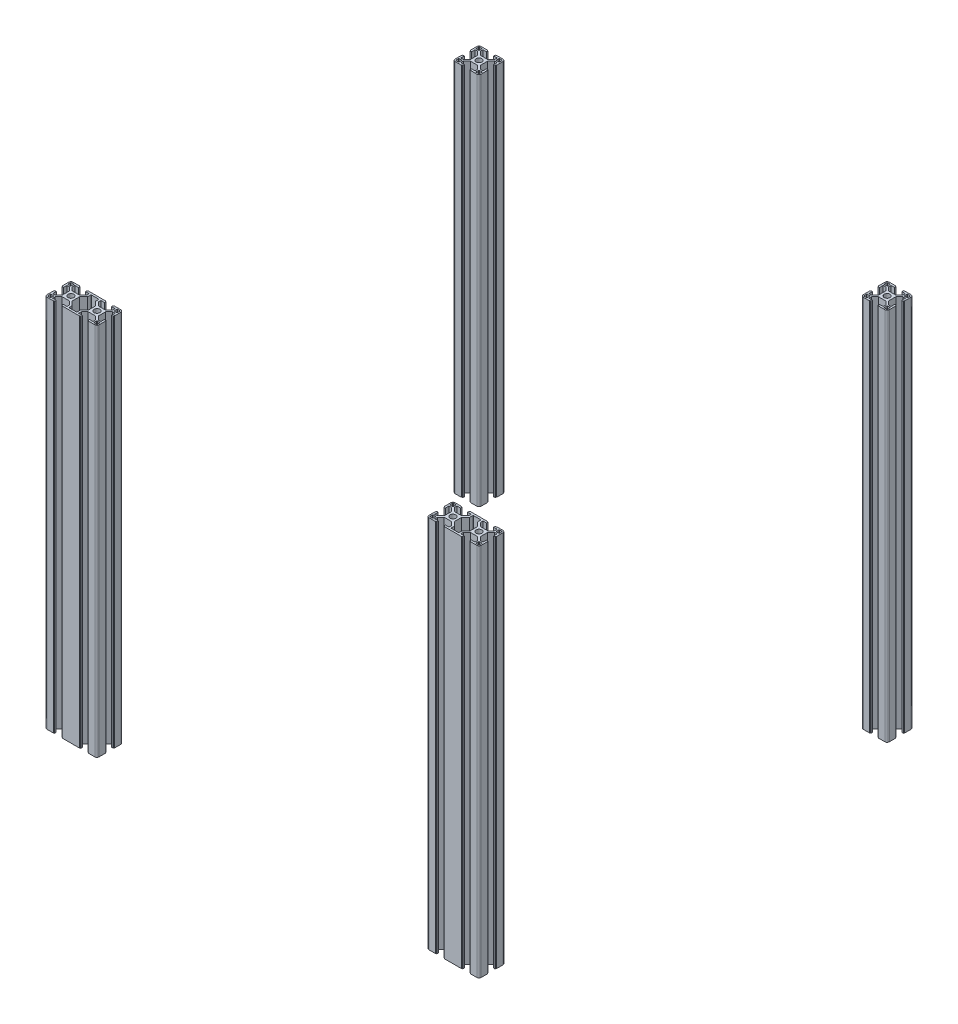
from build123d import *

# Parameters (mm, degrees)
SKETCH1_R               = 3.35
QY_QY_8_3060_1_DEPTH    = 431
SKETCH1_ON_SEGMENT_2_R  = 3.35
QY_QY_8_3060_1_2_DEPTH  = 431
SKETCH11_R              = 3.35
QY_QY_8_3030_1_DEPTH    = 431
SKETCH11_ON_SEGMENT_2_R = 3.35
QY_QY_8_3030_1_2_DEPTH  = 431


with BuildPart() as part:
    # Sketch1 → Qy铝型材 QY-8-3060(1) (new body)
    with BuildSketch(Plane(origin=(-11877.435666185, 11295.577392687, 7.266437545), x_dir=(1, 0, 0), z_dir=(0, -1, 0))):
        with BuildLine():
            Line((-5.2, 15), (-5.2, 14.5))
            Line((-5.2, 14.5), (-4.1, 14.5))
            Line((-4.1, 14.5), (-4.1, 12.8))
            Line((-4.1, 12.8), (-8.25, 12.8))
            Line((-8.25, 12.8), (-8.25, 9.805634919))
            Line((-8.25, 9.805634919), (-4.244365081, 5.8))
            Line((-4.244365081, 5.8), (4.244365081, 5.8))
            Line((4.244365081, 5.8), (8.25, 9.805634919))
            Line((8.25, 9.805634919), (8.25, 12.8))
            Line((8.25, 12.8), (4.1, 12.8))
            Line((4.1, 12.8), (4.1, 14.5))
            Line((4.1, 14.5), (5.2, 14.5))
            Line((5.2, 14.5), (5.2, 15))
            Line((5.2, 15), (24.8, 15))
            Line((24.8, 15), (24.8, 14.5))
            Line((24.8, 14.5), (25.9, 14.5))
            Line((25.9, 14.5), (25.9, 12.8))
            Line((25.9, 12.8), (21.75, 12.8))
            Line((21.75, 12.8), (21.75, 9.805634919))
            Line((21.75, 9.805634919), (25.755634919, 5.8))
            Line((25.755634919, 5.8), (34.244365081, 5.8))
            Line((34.244365081, 5.8), (38.25, 9.805634919))
            Line((38.25, 9.805634919), (38.25, 12.8))
            Line((38.25, 12.8), (34.1, 12.8))
            Line((34.1, 12.8), (34.1, 14.5))
            Line((34.1, 14.5), (35.2, 14.5))
            Line((35.2, 14.5), (35.2, 15))
            Line((35.2, 15), (42.5, 15))
            ThreePointArc((42.5, 15), (44.267766953, 14.267766953), (45, 12.5))
            Line((45, 12.5), (45, 5.075))
            Line((45, 5.075), (44.5, 5.075))
            Line((44.5, 5.075), (44.5, 3.975))
            Line((44.5, 3.975), (42.8, 3.975))
            Line((42.8, 3.975), (42.8, 8.25))
            Line((42.8, 8.25), (39.805634919, 8.25))
            Line((39.805634919, 8.25), (35.8, 4.244365081))
            Line((35.8, 4.244365081), (35.8, -4.244365081))
            Line((35.8, -4.244365081), (39.805634919, -8.25))
            Line((39.805634919, -8.25), (42.8, -8.25))
            Line((42.8, -8.25), (42.8, -4.225))
            Line((42.8, -4.225), (44.5, -4.225))
            Line((44.5, -4.225), (44.5, -5.325))
            Line((44.5, -5.325), (45, -5.325))
            Line((45, -5.325), (45, -12.5))
            ThreePointArc((45, -12.5), (44.267766953, -14.267766953), (42.5, -15))
            Line((42.5, -15), (35.2, -15))
            Line((35.2, -15), (35.2, -14.5))
            Line((35.2, -14.5), (34.1, -14.5))
            Line((34.1, -14.5), (34.1, -12.8))
            Line((34.1, -12.8), (38.25, -12.8))
            Line((38.25, -12.8), (38.25, -9.805634919))
            Line((38.25, -9.805634919), (34.244365081, -5.8))
            Line((34.244365081, -5.8), (25.755634919, -5.8))
            Line((25.755634919, -5.8), (21.75, -9.805634919))
            Line((21.75, -9.805634919), (21.75, -12.8))
            Line((21.75, -12.8), (25.9, -12.8))
            Line((25.9, -12.8), (25.9, -14.5))
            Line((25.9, -14.5), (24.8, -14.5))
            Line((24.8, -14.5), (24.8, -15))
            Line((24.8, -15), (5.2, -15))
            Line((5.2, -15), (5.2, -14.5))
            Line((5.2, -14.5), (4.1, -14.5))
            Line((4.1, -14.5), (4.1, -12.8))
            Line((4.1, -12.8), (8.25, -12.8))
            Line((8.25, -12.8), (8.25, -9.805634919))
            Line((8.25, -9.805634919), (4.244365081, -5.8))
            Line((4.244365081, -5.8), (-4.244365081, -5.8))
            Line((-4.244365081, -5.8), (-8.25, -9.805634919))
            Line((-8.25, -9.805634919), (-8.25, -12.8))
            Line((-8.25, -12.8), (-4.1, -12.8))
            Line((-4.1, -12.8), (-4.1, -14.5))
            Line((-4.1, -14.5), (-5.2, -14.5))
            Line((-5.2, -14.5), (-5.2, -15))
            Line((-5.2, -15), (-12.5, -15))
            ThreePointArc((-12.5, -15), (-14.267766953, -14.267766953), (-15, -12.5))
            Line((-15, -12.5), (-15, -5.325))
            Line((-15, -5.325), (-14.5, -5.325))
            Line((-14.5, -5.325), (-14.5, -4.225))
            Line((-14.5, -4.225), (-12.8, -4.225))
            Line((-12.8, -4.225), (-12.8, -8.25))
            Line((-12.8, -8.25), (-9.805634919, -8.25))
            Line((-9.805634919, -8.25), (-5.8, -4.244365081))
            Line((-5.8, -4.244365081), (-5.8, 4.244365081))
            Line((-5.8, 4.244365081), (-9.805634919, 8.25))
            Line((-9.805634919, 8.25), (-12.8, 8.25))
            Line((-12.8, 8.25), (-12.8, 3.975))
            Line((-12.8, 3.975), (-14.5, 3.975))
            Line((-14.5, 3.975), (-14.5, 5.075))
            Line((-14.5, 5.075), (-15, 5.075))
            Line((-15, 5.075), (-15, 12.5))
            ThreePointArc((-15, 12.5), (-14.267766953, 14.267766953), (-12.5, 15))
            Line((-12.5, 15), (-5.2, 15))
        make_face()
        Circle(SKETCH1_R, mode=Mode.SUBTRACT)
        with Locations((30, 0)):
            Circle(SKETCH1_R, mode=Mode.SUBTRACT)
        with BuildLine():
            Line((10.45, 8.894365081), (5.8, 4.244365081))
            Line((5.8, 4.244365081), (5.8, -4.244365081))
            Line((5.8, -4.244365081), (10.45, -8.894365081))
            Line((10.45, -8.894365081), (10.45, -12.3))
            ThreePointArc((10.45, -12.3), (10.596446609, -12.653553391), (10.95, -12.8))
            Line((10.95, -12.8), (19.05, -12.8))
            ThreePointArc((19.05, -12.8), (19.403553391, -12.653553391), (19.55, -12.3))
            Line((19.55, -12.3), (19.55, -8.894365081))
            Line((19.55, -8.894365081), (24.2, -4.244365081))
            Line((24.2, -4.244365081), (24.2, 4.244365081))
            Line((24.2, 4.244365081), (19.55, 8.894365081))
            Line((19.55, 8.894365081), (19.55, 12.3))
            ThreePointArc((19.55, 12.3), (19.403553391, 12.653553391), (19.05, 12.8))
            Line((19.05, 12.8), (10.95, 12.8))
            ThreePointArc((10.95, 12.8), (10.596446609, 12.653553391), (10.45, 12.3))
            Line((10.45, 12.3), (10.45, 8.894365081))
        make_face(mode=Mode.SUBTRACT)
        with BuildLine():
            Line((-13, 13.5), (-10.25, 13.5))
            ThreePointArc((-10.25, 13.5), (-9.896446609, 13.353553391), (-9.75, 13))
            Line((-9.75, 13), (-9.75, 10.25))
            ThreePointArc((-9.75, 10.25), (-9.896446609, 9.896446609), (-10.25, 9.75))
            Line((-10.25, 9.75), (-13, 9.75))
            ThreePointArc((-13, 9.75), (-13.353553391, 9.896446609), (-13.5, 10.25))
            Line((-13.5, 10.25), (-13.5, 13))
            ThreePointArc((-13.5, 13), (-13.353553391, 13.353553391), (-13, 13.5))
        make_face(mode=Mode.SUBTRACT)
        with BuildLine():
            Line((-9.75, -13), (-9.75, -10.25))
            ThreePointArc((-9.75, -10.25), (-9.896446609, -9.896446609), (-10.25, -9.75))
            Line((-10.25, -9.75), (-13, -9.75))
            ThreePointArc((-13, -9.75), (-13.353553391, -9.896446609), (-13.5, -10.25))
            Line((-13.5, -10.25), (-13.5, -13))
            ThreePointArc((-13.5, -13), (-13.353553391, -13.353553391), (-13, -13.5))
            Line((-13, -13.5), (-10.25, -13.5))
            ThreePointArc((-10.25, -13.5), (-9.896446609, -13.353553391), (-9.75, -13))
        make_face(mode=Mode.SUBTRACT)
        with BuildLine():
            Line((43, -13.5), (40.25, -13.5))
            ThreePointArc((40.25, -13.5), (39.896446609, -13.353553391), (39.75, -13))
            Line((39.75, -13), (39.75, -10.25))
            ThreePointArc((39.75, -10.25), (39.896446609, -9.896446609), (40.25, -9.75))
            Line((40.25, -9.75), (43, -9.75))
            ThreePointArc((43, -9.75), (43.353553391, -9.896446609), (43.5, -10.25))
            Line((43.5, -10.25), (43.5, -13))
            ThreePointArc((43.5, -13), (43.353553391, -13.353553391), (43, -13.5))
        make_face(mode=Mode.SUBTRACT)
        with BuildLine():
            Line((39.75, 13), (39.75, 10.25))
            ThreePointArc((39.75, 10.25), (39.896446609, 9.896446609), (40.25, 9.75))
            Line((40.25, 9.75), (43, 9.75))
            ThreePointArc((43, 9.75), (43.353553391, 9.896446609), (43.5, 10.25))
            Line((43.5, 10.25), (43.5, 13))
            ThreePointArc((43.5, 13), (43.353553391, 13.353553391), (43, 13.5))
            Line((43, 13.5), (40.25, 13.5))
            ThreePointArc((40.25, 13.5), (39.896446609, 13.353553391), (39.75, 13))
        make_face(mode=Mode.SUBTRACT)
    extrude(amount=QY_QY_8_3060_1_DEPTH)


with BuildPart() as body_2:
    # Sketch1 on segment 2 (carried to segment 2) → Qy_ QY-8-3060_1 2 (new body)
    with BuildSketch(Plane(origin=(-11407.435666185, 11295.577392687, 7.266437545), x_dir=(-1, 0, 0), z_dir=(0, -1, 0))):
        with BuildLine():
            Line((-5.2, 15), (-5.2, 14.5))
            Line((-5.2, 14.5), (-4.1, 14.5))
            Line((-4.1, 14.5), (-4.1, 12.8))
            Line((-4.1, 12.8), (-8.25, 12.8))
            Line((-8.25, 12.8), (-8.25, 9.805634919))
            Line((-8.25, 9.805634919), (-4.244365081, 5.8))
            Line((-4.244365081, 5.8), (4.244365081, 5.8))
            Line((4.244365081, 5.8), (8.25, 9.805634919))
            Line((8.25, 9.805634919), (8.25, 12.8))
            Line((8.25, 12.8), (4.1, 12.8))
            Line((4.1, 12.8), (4.1, 14.5))
            Line((4.1, 14.5), (5.2, 14.5))
            Line((5.2, 14.5), (5.2, 15))
            Line((5.2, 15), (24.8, 15))
            Line((24.8, 15), (24.8, 14.5))
            Line((24.8, 14.5), (25.9, 14.5))
            Line((25.9, 14.5), (25.9, 12.8))
            Line((25.9, 12.8), (21.75, 12.8))
            Line((21.75, 12.8), (21.75, 9.805634919))
            Line((21.75, 9.805634919), (25.755634919, 5.8))
            Line((25.755634919, 5.8), (34.244365081, 5.8))
            Line((34.244365081, 5.8), (38.25, 9.805634919))
            Line((38.25, 9.805634919), (38.25, 12.8))
            Line((38.25, 12.8), (34.1, 12.8))
            Line((34.1, 12.8), (34.1, 14.5))
            Line((34.1, 14.5), (35.2, 14.5))
            Line((35.2, 14.5), (35.2, 15))
            Line((35.2, 15), (42.5, 15))
            ThreePointArc((42.5, 15), (44.267766953, 14.267766953), (45, 12.5))
            Line((45, 12.5), (45, 5.075))
            Line((45, 5.075), (44.5, 5.075))
            Line((44.5, 5.075), (44.5, 3.975))
            Line((44.5, 3.975), (42.8, 3.975))
            Line((42.8, 3.975), (42.8, 8.25))
            Line((42.8, 8.25), (39.805634919, 8.25))
            Line((39.805634919, 8.25), (35.8, 4.244365081))
            Line((35.8, 4.244365081), (35.8, -4.244365081))
            Line((35.8, -4.244365081), (39.805634919, -8.25))
            Line((39.805634919, -8.25), (42.8, -8.25))
            Line((42.8, -8.25), (42.8, -4.225))
            Line((42.8, -4.225), (44.5, -4.225))
            Line((44.5, -4.225), (44.5, -5.325))
            Line((44.5, -5.325), (45, -5.325))
            Line((45, -5.325), (45, -12.5))
            ThreePointArc((45, -12.5), (44.267766953, -14.267766953), (42.5, -15))
            Line((42.5, -15), (35.2, -15))
            Line((35.2, -15), (35.2, -14.5))
            Line((35.2, -14.5), (34.1, -14.5))
            Line((34.1, -14.5), (34.1, -12.8))
            Line((34.1, -12.8), (38.25, -12.8))
            Line((38.25, -12.8), (38.25, -9.805634919))
            Line((38.25, -9.805634919), (34.244365081, -5.8))
            Line((34.244365081, -5.8), (25.755634919, -5.8))
            Line((25.755634919, -5.8), (21.75, -9.805634919))
            Line((21.75, -9.805634919), (21.75, -12.8))
            Line((21.75, -12.8), (25.9, -12.8))
            Line((25.9, -12.8), (25.9, -14.5))
            Line((25.9, -14.5), (24.8, -14.5))
            Line((24.8, -14.5), (24.8, -15))
            Line((24.8, -15), (5.2, -15))
            Line((5.2, -15), (5.2, -14.5))
            Line((5.2, -14.5), (4.1, -14.5))
            Line((4.1, -14.5), (4.1, -12.8))
            Line((4.1, -12.8), (8.25, -12.8))
            Line((8.25, -12.8), (8.25, -9.805634919))
            Line((8.25, -9.805634919), (4.244365081, -5.8))
            Line((4.244365081, -5.8), (-4.244365081, -5.8))
            Line((-4.244365081, -5.8), (-8.25, -9.805634919))
            Line((-8.25, -9.805634919), (-8.25, -12.8))
            Line((-8.25, -12.8), (-4.1, -12.8))
            Line((-4.1, -12.8), (-4.1, -14.5))
            Line((-4.1, -14.5), (-5.2, -14.5))
            Line((-5.2, -14.5), (-5.2, -15))
            Line((-5.2, -15), (-12.5, -15))
            ThreePointArc((-12.5, -15), (-14.267766953, -14.267766953), (-15, -12.5))
            Line((-15, -12.5), (-15, -5.325))
            Line((-15, -5.325), (-14.5, -5.325))
            Line((-14.5, -5.325), (-14.5, -4.225))
            Line((-14.5, -4.225), (-12.8, -4.225))
            Line((-12.8, -4.225), (-12.8, -8.25))
            Line((-12.8, -8.25), (-9.805634919, -8.25))
            Line((-9.805634919, -8.25), (-5.8, -4.244365081))
            Line((-5.8, -4.244365081), (-5.8, 4.244365081))
            Line((-5.8, 4.244365081), (-9.805634919, 8.25))
            Line((-9.805634919, 8.25), (-12.8, 8.25))
            Line((-12.8, 8.25), (-12.8, 3.975))
            Line((-12.8, 3.975), (-14.5, 3.975))
            Line((-14.5, 3.975), (-14.5, 5.075))
            Line((-14.5, 5.075), (-15, 5.075))
            Line((-15, 5.075), (-15, 12.5))
            ThreePointArc((-15, 12.5), (-14.267766953, 14.267766953), (-12.5, 15))
            Line((-12.5, 15), (-5.2, 15))
        make_face()
        Circle(SKETCH1_ON_SEGMENT_2_R, mode=Mode.SUBTRACT)
        with Locations((30, 0)):
            Circle(SKETCH1_ON_SEGMENT_2_R, mode=Mode.SUBTRACT)
        with BuildLine():
            Line((10.45, 8.894365081), (5.8, 4.244365081))
            Line((5.8, 4.244365081), (5.8, -4.244365081))
            Line((5.8, -4.244365081), (10.45, -8.894365081))
            Line((10.45, -8.894365081), (10.45, -12.3))
            ThreePointArc((10.45, -12.3), (10.596446609, -12.653553391), (10.95, -12.8))
            Line((10.95, -12.8), (19.05, -12.8))
            ThreePointArc((19.05, -12.8), (19.403553391, -12.653553391), (19.55, -12.3))
            Line((19.55, -12.3), (19.55, -8.894365081))
            Line((19.55, -8.894365081), (24.2, -4.244365081))
            Line((24.2, -4.244365081), (24.2, 4.244365081))
            Line((24.2, 4.244365081), (19.55, 8.894365081))
            Line((19.55, 8.894365081), (19.55, 12.3))
            ThreePointArc((19.55, 12.3), (19.403553391, 12.653553391), (19.05, 12.8))
            Line((19.05, 12.8), (10.95, 12.8))
            ThreePointArc((10.95, 12.8), (10.596446609, 12.653553391), (10.45, 12.3))
            Line((10.45, 12.3), (10.45, 8.894365081))
        make_face(mode=Mode.SUBTRACT)
        with BuildLine():
            Line((-13, 13.5), (-10.25, 13.5))
            ThreePointArc((-10.25, 13.5), (-9.896446609, 13.353553391), (-9.75, 13))
            Line((-9.75, 13), (-9.75, 10.25))
            ThreePointArc((-9.75, 10.25), (-9.896446609, 9.896446609), (-10.25, 9.75))
            Line((-10.25, 9.75), (-13, 9.75))
            ThreePointArc((-13, 9.75), (-13.353553391, 9.896446609), (-13.5, 10.25))
            Line((-13.5, 10.25), (-13.5, 13))
            ThreePointArc((-13.5, 13), (-13.353553391, 13.353553391), (-13, 13.5))
        make_face(mode=Mode.SUBTRACT)
        with BuildLine():
            Line((-9.75, -13), (-9.75, -10.25))
            ThreePointArc((-9.75, -10.25), (-9.896446609, -9.896446609), (-10.25, -9.75))
            Line((-10.25, -9.75), (-13, -9.75))
            ThreePointArc((-13, -9.75), (-13.353553391, -9.896446609), (-13.5, -10.25))
            Line((-13.5, -10.25), (-13.5, -13))
            ThreePointArc((-13.5, -13), (-13.353553391, -13.353553391), (-13, -13.5))
            Line((-13, -13.5), (-10.25, -13.5))
            ThreePointArc((-10.25, -13.5), (-9.896446609, -13.353553391), (-9.75, -13))
        make_face(mode=Mode.SUBTRACT)
        with BuildLine():
            Line((43, -13.5), (40.25, -13.5))
            ThreePointArc((40.25, -13.5), (39.896446609, -13.353553391), (39.75, -13))
            Line((39.75, -13), (39.75, -10.25))
            ThreePointArc((39.75, -10.25), (39.896446609, -9.896446609), (40.25, -9.75))
            Line((40.25, -9.75), (43, -9.75))
            ThreePointArc((43, -9.75), (43.353553391, -9.896446609), (43.5, -10.25))
            Line((43.5, -10.25), (43.5, -13))
            ThreePointArc((43.5, -13), (43.353553391, -13.353553391), (43, -13.5))
        make_face(mode=Mode.SUBTRACT)
        with BuildLine():
            Line((39.75, 13), (39.75, 10.25))
            ThreePointArc((39.75, 10.25), (39.896446609, 9.896446609), (40.25, 9.75))
            Line((40.25, 9.75), (43, 9.75))
            ThreePointArc((43, 9.75), (43.353553391, 9.896446609), (43.5, 10.25))
            Line((43.5, 10.25), (43.5, 13))
            ThreePointArc((43.5, 13), (43.353553391, 13.353553391), (43, 13.5))
            Line((43, 13.5), (40.25, 13.5))
            ThreePointArc((40.25, 13.5), (39.896446609, 13.353553391), (39.75, 13))
        make_face(mode=Mode.SUBTRACT)
    extrude(amount=QY_QY_8_3060_1_2_DEPTH)


with BuildPart() as body_3:
    # Sketch11 → Qy铝型材 QY-8-3030(1) (new body)
    with BuildSketch(Plane(origin=(-11407.435666185, 11295.577392687, -462.733562455), x_dir=(1, 0, 0), z_dir=(0, -1, 0))):
        with BuildLine():
            Line((-5.2, 15), (-5.2, 14.5))
            Line((-5.2, 14.5), (-4.1, 14.5))
            Line((-4.1, 14.5), (-4.1, 12.8))
            Line((-4.1, 12.8), (-8.25, 12.8))
            Line((-8.25, 12.8), (-8.25, 9.8))
            Line((-8.25, 9.8), (-4.25, 5.8))
            Line((-4.25, 5.8), (4.25, 5.8))
            Line((4.25, 5.8), (8.25, 9.8))
            Line((8.25, 9.8), (8.25, 12.8))
            Line((8.25, 12.8), (4.1, 12.8))
            Line((4.1, 12.8), (4.1, 14.5))
            Line((4.1, 14.5), (5.2, 14.5))
            Line((5.2, 14.5), (5.2, 15))
            Line((5.2, 15), (12.5, 15))
            ThreePointArc((12.5, 15), (14.267766953, 14.267766953), (15, 12.5))
            Line((15, 12.5), (15, 5.2))
            Line((15, 5.2), (14.5, 5.2))
            Line((14.5, 5.2), (14.5, 4.1))
            Line((14.5, 4.1), (12.8, 4.1))
            Line((12.8, 4.1), (12.8, 8.25))
            Line((12.8, 8.25), (9.8, 8.25))
            Line((9.8, 8.25), (5.8, 4.25))
            Line((5.8, 4.25), (5.8, -4.25))
            Line((5.8, -4.25), (9.8, -8.25))
            Line((9.8, -8.25), (12.8, -8.25))
            Line((12.8, -8.25), (12.8, -4.1))
            Line((12.8, -4.1), (14.5, -4.1))
            Line((14.5, -4.1), (14.5, -5.2))
            Line((14.5, -5.2), (15, -5.2))
            Line((15, -5.2), (15, -12.5))
            ThreePointArc((15, -12.5), (14.267766953, -14.267766953), (12.5, -15))
            Line((12.5, -15), (5.2, -15))
            Line((5.2, -15), (5.2, -14.5))
            Line((5.2, -14.5), (4.1, -14.5))
            Line((4.1, -14.5), (4.1, -12.8))
            Line((4.1, -12.8), (8.25, -12.8))
            Line((8.25, -12.8), (8.25, -9.8))
            Line((8.25, -9.8), (4.25, -5.8))
            Line((4.25, -5.8), (-4.25, -5.8))
            Line((-4.25, -5.8), (-8.25, -9.8))
            Line((-8.25, -9.8), (-8.25, -12.8))
            Line((-8.25, -12.8), (-4.1, -12.8))
            Line((-4.1, -12.8), (-4.1, -14.5))
            Line((-4.1, -14.5), (-5.2, -14.5))
            Line((-5.2, -14.5), (-5.2, -15))
            Line((-5.2, -15), (-12.5, -15))
            ThreePointArc((-12.5, -15), (-14.267766953, -14.267766953), (-15, -12.5))
            Line((-15, -12.5), (-15, -5.2))
            Line((-15, -5.2), (-14.5, -5.2))
            Line((-14.5, -5.2), (-14.5, -4.1))
            Line((-14.5, -4.1), (-12.8, -4.1))
            Line((-12.8, -4.1), (-12.8, -8.25))
            Line((-12.8, -8.25), (-9.8, -8.25))
            Line((-9.8, -8.25), (-5.8, -4.25))
            Line((-5.8, -4.25), (-5.8, 4.25))
            Line((-5.8, 4.25), (-9.8, 8.25))
            Line((-9.8, 8.25), (-12.8, 8.25))
            Line((-12.8, 8.25), (-12.8, 4.1))
            Line((-12.8, 4.1), (-14.5, 4.1))
            Line((-14.5, 4.1), (-14.5, 5.2))
            Line((-14.5, 5.2), (-15, 5.2))
            Line((-15, 5.2), (-15, 12.5))
            ThreePointArc((-15, 12.5), (-14.267766953, 14.267766953), (-12.5, 15))
            Line((-12.5, 15), (-5.2, 15))
        make_face()
        Circle(SKETCH11_R, mode=Mode.SUBTRACT)
        with BuildLine():
            Line((-13, 13.5), (-10.25, 13.5))
            ThreePointArc((-10.25, 13.5), (-9.896446609, 13.353553391), (-9.75, 13))
            Line((-9.75, 13), (-9.75, 10.25))
            ThreePointArc((-9.75, 10.25), (-9.896446609, 9.896446609), (-10.25, 9.75))
            Line((-10.25, 9.75), (-13, 9.75))
            ThreePointArc((-13, 9.75), (-13.353553391, 9.896446609), (-13.5, 10.25))
            Line((-13.5, 10.25), (-13.5, 13))
            ThreePointArc((-13.5, 13), (-13.353553391, 13.353553391), (-13, 13.5))
        make_face(mode=Mode.SUBTRACT)
        with BuildLine():
            Line((9.75, 13), (9.75, 10.25))
            ThreePointArc((9.75, 10.25), (9.896446609, 9.896446609), (10.25, 9.75))
            Line((10.25, 9.75), (13, 9.75))
            ThreePointArc((13, 9.75), (13.353553391, 9.896446609), (13.5, 10.25))
            Line((13.5, 10.25), (13.5, 13))
            ThreePointArc((13.5, 13), (13.353553391, 13.353553391), (13, 13.5))
            Line((13, 13.5), (10.25, 13.5))
            ThreePointArc((10.25, 13.5), (9.896446609, 13.353553391), (9.75, 13))
        make_face(mode=Mode.SUBTRACT)
        with BuildLine():
            Line((-9.75, -13), (-9.75, -10.25))
            ThreePointArc((-9.75, -10.25), (-9.896446609, -9.896446609), (-10.25, -9.75))
            Line((-10.25, -9.75), (-13, -9.75))
            ThreePointArc((-13, -9.75), (-13.353553391, -9.896446609), (-13.5, -10.25))
            Line((-13.5, -10.25), (-13.5, -13))
            ThreePointArc((-13.5, -13), (-13.353553391, -13.353553391), (-13, -13.5))
            Line((-13, -13.5), (-10.25, -13.5))
            ThreePointArc((-10.25, -13.5), (-9.896446609, -13.353553391), (-9.75, -13))
        make_face(mode=Mode.SUBTRACT)
        with BuildLine():
            Line((13, -13.5), (10.25, -13.5))
            ThreePointArc((10.25, -13.5), (9.896446609, -13.353553391), (9.75, -13))
            Line((9.75, -13), (9.75, -10.25))
            ThreePointArc((9.75, -10.25), (9.896446609, -9.896446609), (10.25, -9.75))
            Line((10.25, -9.75), (13, -9.75))
            ThreePointArc((13, -9.75), (13.353553391, -9.896446609), (13.5, -10.25))
            Line((13.5, -10.25), (13.5, -13))
            ThreePointArc((13.5, -13), (13.353553391, -13.353553391), (13, -13.5))
        make_face(mode=Mode.SUBTRACT)
    extrude(amount=QY_QY_8_3030_1_DEPTH)


with BuildPart() as body_4:
    # Sketch11 on segment 2 (carried to segment 2) → Qy_ QY-8-3030_1 2 (new body)
    with BuildSketch(Plane(origin=(-11877.435666185, 11295.577392687, -462.733562455), x_dir=(1, 0, 0), z_dir=(0, -1, 0))):
        with BuildLine():
            Line((-5.2, 15), (-5.2, 14.5))
            Line((-5.2, 14.5), (-4.1, 14.5))
            Line((-4.1, 14.5), (-4.1, 12.8))
            Line((-4.1, 12.8), (-8.25, 12.8))
            Line((-8.25, 12.8), (-8.25, 9.8))
            Line((-8.25, 9.8), (-4.25, 5.8))
            Line((-4.25, 5.8), (4.25, 5.8))
            Line((4.25, 5.8), (8.25, 9.8))
            Line((8.25, 9.8), (8.25, 12.8))
            Line((8.25, 12.8), (4.1, 12.8))
            Line((4.1, 12.8), (4.1, 14.5))
            Line((4.1, 14.5), (5.2, 14.5))
            Line((5.2, 14.5), (5.2, 15))
            Line((5.2, 15), (12.5, 15))
            ThreePointArc((12.5, 15), (14.267766953, 14.267766953), (15, 12.5))
            Line((15, 12.5), (15, 5.2))
            Line((15, 5.2), (14.5, 5.2))
            Line((14.5, 5.2), (14.5, 4.1))
            Line((14.5, 4.1), (12.8, 4.1))
            Line((12.8, 4.1), (12.8, 8.25))
            Line((12.8, 8.25), (9.8, 8.25))
            Line((9.8, 8.25), (5.8, 4.25))
            Line((5.8, 4.25), (5.8, -4.25))
            Line((5.8, -4.25), (9.8, -8.25))
            Line((9.8, -8.25), (12.8, -8.25))
            Line((12.8, -8.25), (12.8, -4.1))
            Line((12.8, -4.1), (14.5, -4.1))
            Line((14.5, -4.1), (14.5, -5.2))
            Line((14.5, -5.2), (15, -5.2))
            Line((15, -5.2), (15, -12.5))
            ThreePointArc((15, -12.5), (14.267766953, -14.267766953), (12.5, -15))
            Line((12.5, -15), (5.2, -15))
            Line((5.2, -15), (5.2, -14.5))
            Line((5.2, -14.5), (4.1, -14.5))
            Line((4.1, -14.5), (4.1, -12.8))
            Line((4.1, -12.8), (8.25, -12.8))
            Line((8.25, -12.8), (8.25, -9.8))
            Line((8.25, -9.8), (4.25, -5.8))
            Line((4.25, -5.8), (-4.25, -5.8))
            Line((-4.25, -5.8), (-8.25, -9.8))
            Line((-8.25, -9.8), (-8.25, -12.8))
            Line((-8.25, -12.8), (-4.1, -12.8))
            Line((-4.1, -12.8), (-4.1, -14.5))
            Line((-4.1, -14.5), (-5.2, -14.5))
            Line((-5.2, -14.5), (-5.2, -15))
            Line((-5.2, -15), (-12.5, -15))
            ThreePointArc((-12.5, -15), (-14.267766953, -14.267766953), (-15, -12.5))
            Line((-15, -12.5), (-15, -5.2))
            Line((-15, -5.2), (-14.5, -5.2))
            Line((-14.5, -5.2), (-14.5, -4.1))
            Line((-14.5, -4.1), (-12.8, -4.1))
            Line((-12.8, -4.1), (-12.8, -8.25))
            Line((-12.8, -8.25), (-9.8, -8.25))
            Line((-9.8, -8.25), (-5.8, -4.25))
            Line((-5.8, -4.25), (-5.8, 4.25))
            Line((-5.8, 4.25), (-9.8, 8.25))
            Line((-9.8, 8.25), (-12.8, 8.25))
            Line((-12.8, 8.25), (-12.8, 4.1))
            Line((-12.8, 4.1), (-14.5, 4.1))
            Line((-14.5, 4.1), (-14.5, 5.2))
            Line((-14.5, 5.2), (-15, 5.2))
            Line((-15, 5.2), (-15, 12.5))
            ThreePointArc((-15, 12.5), (-14.267766953, 14.267766953), (-12.5, 15))
            Line((-12.5, 15), (-5.2, 15))
        make_face()
        Circle(SKETCH11_ON_SEGMENT_2_R, mode=Mode.SUBTRACT)
        with BuildLine():
            Line((-13, 13.5), (-10.25, 13.5))
            ThreePointArc((-10.25, 13.5), (-9.896446609, 13.353553391), (-9.75, 13))
            Line((-9.75, 13), (-9.75, 10.25))
            ThreePointArc((-9.75, 10.25), (-9.896446609, 9.896446609), (-10.25, 9.75))
            Line((-10.25, 9.75), (-13, 9.75))
            ThreePointArc((-13, 9.75), (-13.353553391, 9.896446609), (-13.5, 10.25))
            Line((-13.5, 10.25), (-13.5, 13))
            ThreePointArc((-13.5, 13), (-13.353553391, 13.353553391), (-13, 13.5))
        make_face(mode=Mode.SUBTRACT)
        with BuildLine():
            Line((9.75, 13), (9.75, 10.25))
            ThreePointArc((9.75, 10.25), (9.896446609, 9.896446609), (10.25, 9.75))
            Line((10.25, 9.75), (13, 9.75))
            ThreePointArc((13, 9.75), (13.353553391, 9.896446609), (13.5, 10.25))
            Line((13.5, 10.25), (13.5, 13))
            ThreePointArc((13.5, 13), (13.353553391, 13.353553391), (13, 13.5))
            Line((13, 13.5), (10.25, 13.5))
            ThreePointArc((10.25, 13.5), (9.896446609, 13.353553391), (9.75, 13))
        make_face(mode=Mode.SUBTRACT)
        with BuildLine():
            Line((-9.75, -13), (-9.75, -10.25))
            ThreePointArc((-9.75, -10.25), (-9.896446609, -9.896446609), (-10.25, -9.75))
            Line((-10.25, -9.75), (-13, -9.75))
            ThreePointArc((-13, -9.75), (-13.353553391, -9.896446609), (-13.5, -10.25))
            Line((-13.5, -10.25), (-13.5, -13))
            ThreePointArc((-13.5, -13), (-13.353553391, -13.353553391), (-13, -13.5))
            Line((-13, -13.5), (-10.25, -13.5))
            ThreePointArc((-10.25, -13.5), (-9.896446609, -13.353553391), (-9.75, -13))
        make_face(mode=Mode.SUBTRACT)
        with BuildLine():
            Line((13, -13.5), (10.25, -13.5))
            ThreePointArc((10.25, -13.5), (9.896446609, -13.353553391), (9.75, -13))
            Line((9.75, -13), (9.75, -10.25))
            ThreePointArc((9.75, -10.25), (9.896446609, -9.896446609), (10.25, -9.75))
            Line((10.25, -9.75), (13, -9.75))
            ThreePointArc((13, -9.75), (13.353553391, -9.896446609), (13.5, -10.25))
            Line((13.5, -10.25), (13.5, -13))
            ThreePointArc((13.5, -13), (13.353553391, -13.353553391), (13, -13.5))
        make_face(mode=Mode.SUBTRACT)
    extrude(amount=QY_QY_8_3030_1_2_DEPTH)


solid = Compound([part.part, body_2.part, body_3.part, body_4.part])
